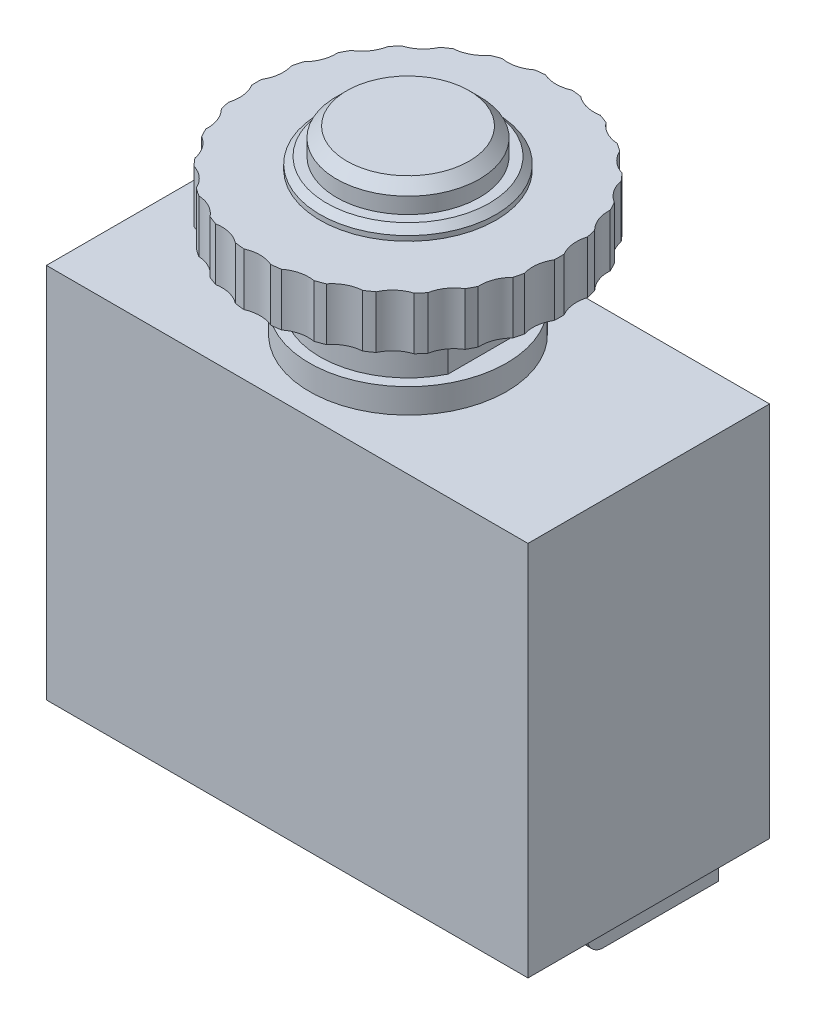
from build123d import *

# Parameters (mm, degrees)
SKETCH2_W           = 29.3
SKETCH2_H           = 14.7
BOSS_EXTRUDE1_DEPTH = 22.9
BOSS_EXTRUDE2_START = 5
BOSS_EXTRUDE2_DEPTH = 6.35
SKETCH8_R           = 1
CUT_EXTRUDE3_DEPTH  = 0.9
SKETCH5_R           = 2
CUT_EXTRUDE1_DEPTH  = 3.2
CIRPATTERN1_COUNT   = 26
SKETCH7_W           = 0.55
SKETCH7_H           = 4
CUT_EXTRUDE2_DEPTH  = 17.523822727
FILLET1_R           = 0.1
FILLET1_2_R         = 1


with BuildPart() as part:
    # Sketch2 → Boss-Extrude1 (new body)
    with BuildSketch(Plane(origin=(0, 0, 0), x_dir=(1, 0, 0), z_dir=(0, 1, 0))):
        Rectangle(SKETCH2_W, SKETCH2_H)
    extrude(amount=BOSS_EXTRUDE1_DEPTH)

    # Sketch3 → Revolve1 (revolve)
    with BuildSketch(Plane.XY):
        Polygon((0, 22.9), (0, 33.9), (-3.72, 33.9), (-4.35, 33.27), (-4.35, 32.3), (-4.95, 32.3), (-5.35, 31.9), (-5.35, 31.6), (-9.21, 31.6), (-9.21, 28.4), (-5.35, 28.4), (-5.35, 24.4), (-6, 24.4), (-6, 22.9), align=None)
    revolve(axis=Axis((0, 22.9, 0), (0, 1, 0)))

    # Sketch4 → Boss-Extrude2 (add)
    with BuildSketch(Plane(origin=(0, 0, 0), x_dir=(0, 0, -1), z_dir=(1, 0, 0)).offset(BOSS_EXTRUDE2_START)):
        Polygon((-0.45, -4), (0.45, -4), (7.55, -4), (7.55, -3.1), (0.45, -3.1), (0.45, 0), (-0.45, 0), align=None)
    boss_extrude2 = extrude(amount=BOSS_EXTRUDE2_DEPTH)

    # Sketch8 → Cut-Extrude3 (cut)
    with BuildSketch(Plane.XZ.offset(4)):
        with Locations((8.175, -5.55)):
            Circle(SKETCH8_R)
    cut_extrude3 = extrude(amount=-CUT_EXTRUDE3_DEPTH, mode=Mode.SUBTRACT)

    # Mirror1: Boss-Extrude2, Cut-Extrude3 across plane
    add(boss_extrude2.mirror(Plane(origin=(0, 0, 0), x_dir=(0, 0, 1), z_dir=(1, 0, 0))))
    add(cut_extrude3.mirror(Plane(origin=(0, 0, 0), x_dir=(0, 0, 1), z_dir=(1, 0, 0))), mode=Mode.SUBTRACT)

    # Sketch5 → Cut-Extrude1 (cut)
    with BuildSketch(Plane(origin=(0, 31.6, 0), x_dir=(1, 0, 0), z_dir=(0, 1, 0))):
        with Locations((0, 11)):
            Circle(SKETCH5_R)
    cut_extrude1 = extrude(amount=-CUT_EXTRUDE1_DEPTH, mode=Mode.SUBTRACT)

    # CirPattern1: Cut-Extrude1 ×26 about axis
    cirpattern1_axis = Axis((0, 0, 0), (0, 1, 0))
    for i in range(1, CIRPATTERN1_COUNT):
        add(cut_extrude1.rotate(cirpattern1_axis, i * 360 / CIRPATTERN1_COUNT), mode=Mode.SUBTRACT)

    # Sketch7 → Cut-Extrude2 (cut, through all)
    with BuildSketch(Plane.XY.offset(7.35)):
        with Locations((5.075, 26.4)):
            Rectangle(SKETCH7_W, SKETCH7_H)
        with Locations((-5.075, 26.4)):
            Rectangle(SKETCH7_W, SKETCH7_H)
    extrude(amount=-CUT_EXTRUDE2_DEPTH, mode=Mode.SUBTRACT)

    # Fillet1
    fillet1_edges = [part.edges().sort_by_distance(p)[0] for p in [
        (8.175, -3.1, -0.45),
        (-8.175, -3.1, -0.45),
    ]]
    fillet(fillet1_edges, radius=FILLET1_R)

    # Fillet1 2
    fillet1_2_edges = [part.edges().sort_by_distance(p)[0] for p in [
        (8.175, -4, 0.45),
        (-8.175, -4, 0.45),
    ]]
    fillet(fillet1_2_edges, radius=FILLET1_2_R)


solid = part.part
